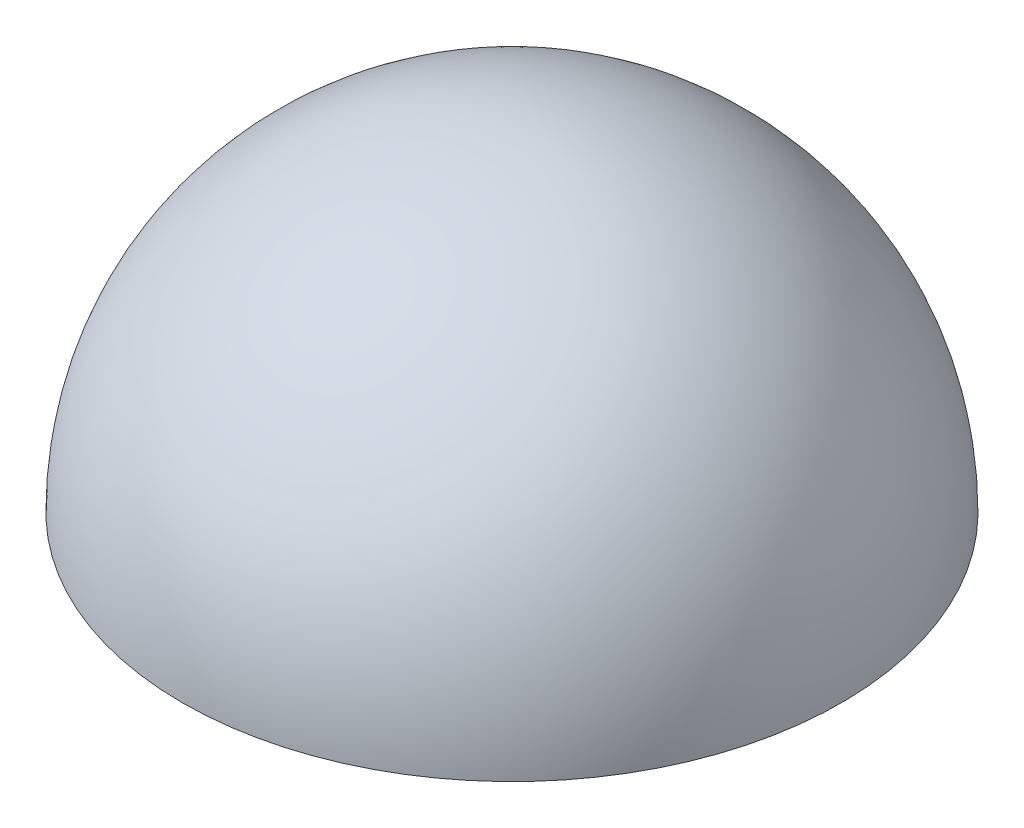
from build123d import *

# Parameters (mm, degrees)
REVOLVE3_ANGLE = 180


with BuildPart() as part:
    # Sketch1 → Revolve3 (revolve)
    with BuildSketch(Plane(origin=(0, 0, 0), x_dir=(1, 0, 0), z_dir=(0, 1, 0))):
        with BuildLine():
            Line((0, 0), (0, 50))
            ThreePointArc((0, 50), (25, 25), (0, 0))
        make_face()
    revolve(axis=Axis((0, 0, 0), (0, 0, 1)), revolution_arc=REVOLVE3_ANGLE)


solid = part.part
